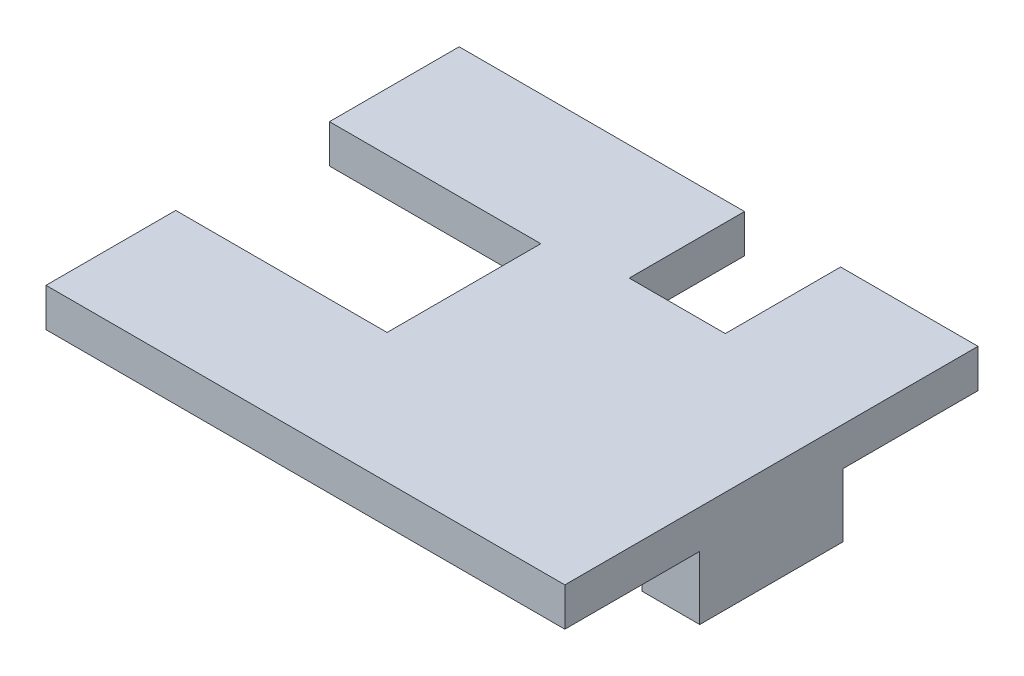
from build123d import *

# Parameters (mm, degrees)
BOSS_EXTRUDE1_DEPTH = 2
SKETCH2_W           = 3
SKETCH2_H           = 7.46
BOSS_EXTRUDE2_DEPTH = 3.3


with BuildPart() as part:
    # Sketch1 → Boss-Extrude1 (new body)
    with BuildSketch(Plane(origin=(0, 0, 0), x_dir=(1, 0, 0), z_dir=(0, 1, 0))):
        Polygon((-19.033651007, 9.961336175), (-4.183651007, 9.961336175), (-4.183651007, 3.961336175), (0.816348993, 3.961336175), (0.816348993, 9.961336175), (7.966348993, 9.961336175), (7.966348993, -11.538663825), (-19.033651007, -11.538663825), (-19.033651007, -4.788663825), (-8.033651007, -4.788663825), (-8.033651007, 3.211336175), (-19.033651007, 3.211336175), align=None)
    extrude(amount=BOSS_EXTRUDE1_DEPTH)

    # Sketch2 → Boss-Extrude2 (add)
    with BuildSketch(Plane.XZ):
        with Locations((6.466348993, 0.788663825)):
            Rectangle(SKETCH2_W, SKETCH2_H)
    extrude(amount=BOSS_EXTRUDE2_DEPTH)


solid = part.part
